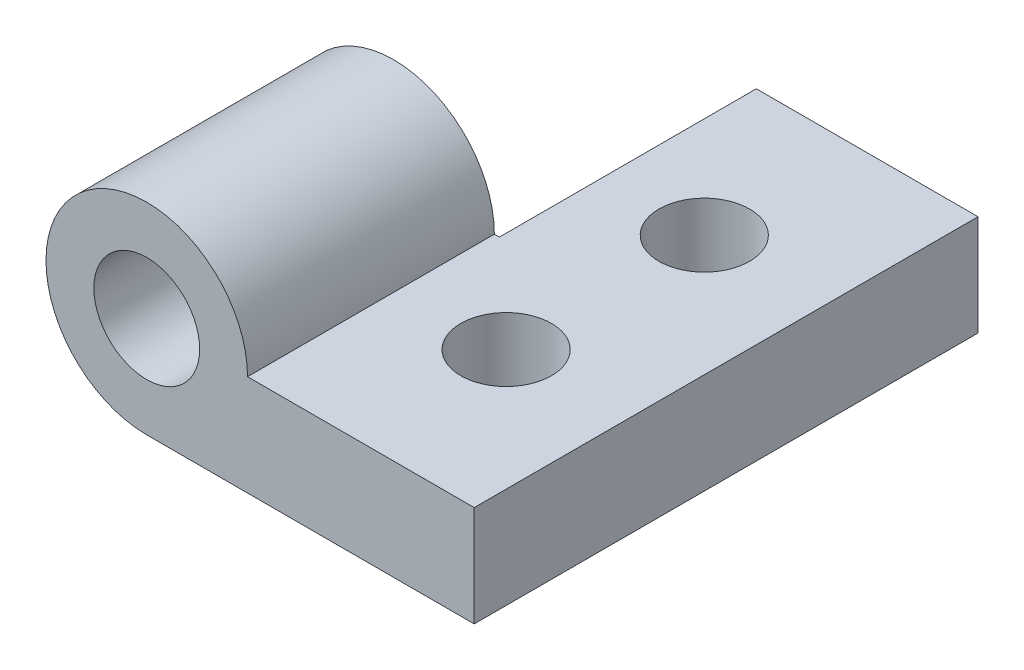
from build123d import *

# Parameters (mm, degrees)
BOSS_EXTRUDE1_DEPTH = 25.4
SKETCH5_R           = 2.286
CUT_EXTRUDE3_DEPTH  = 12.954
SKETCH8_R           = 5.334
CUT_EXTRUDE5_DEPTH  = 12.954
SKETCH9_R           = 2.667
CUT_EXTRUDE6_DEPTH  = 12.7


with BuildPart() as part:
    # Sketch2 → Boss-Extrude1 (new body)
    with BuildSketch(Plane.XY):
        with BuildLine():
            Line((0, 0), (-16.51, 0))
            ThreePointArc((-16.51, 0), (-20.102102448, 8.672102448), (-11.43, 5.08))
            Line((-11.43, 5.08), (0, 5.08))
            Line((0, 5.08), (0, 0))
        make_face()
    extrude(amount=BOSS_EXTRUDE1_DEPTH)

    # Sketch5 → Cut-Extrude3 (cut)
    with BuildSketch(Plane(origin=(0, 5.08, 0), x_dir=(1, 0, 0), z_dir=(0, 1, 0))):
        with Locations((-6.096, -17.695333333)):
            Circle(SKETCH5_R)
        with Locations((-6.096, -7.704666667)):
            Circle(SKETCH5_R)
    extrude(amount=-CUT_EXTRUDE3_DEPTH, mode=Mode.SUBTRACT)

    # Sketch8 → Cut-Extrude5 (cut)
    with BuildSketch(Plane(origin=(0, 0, 0), x_dir=(-1, 0, 0), z_dir=(0, 0, -1))):
        with Locations((16.51, 5.08)):
            Circle(SKETCH8_R)
    extrude(amount=-CUT_EXTRUDE5_DEPTH, mode=Mode.SUBTRACT)

    # Sketch9 → Cut-Extrude6 (cut)
    with BuildSketch(Plane(origin=(0, 0, 12.954), x_dir=(-1, 0, 0), z_dir=(0, 0, -1))):
        with Locations((16.51, 5.08)):
            Circle(SKETCH9_R)
    extrude(amount=-CUT_EXTRUDE6_DEPTH, mode=Mode.SUBTRACT)


solid = part.part
